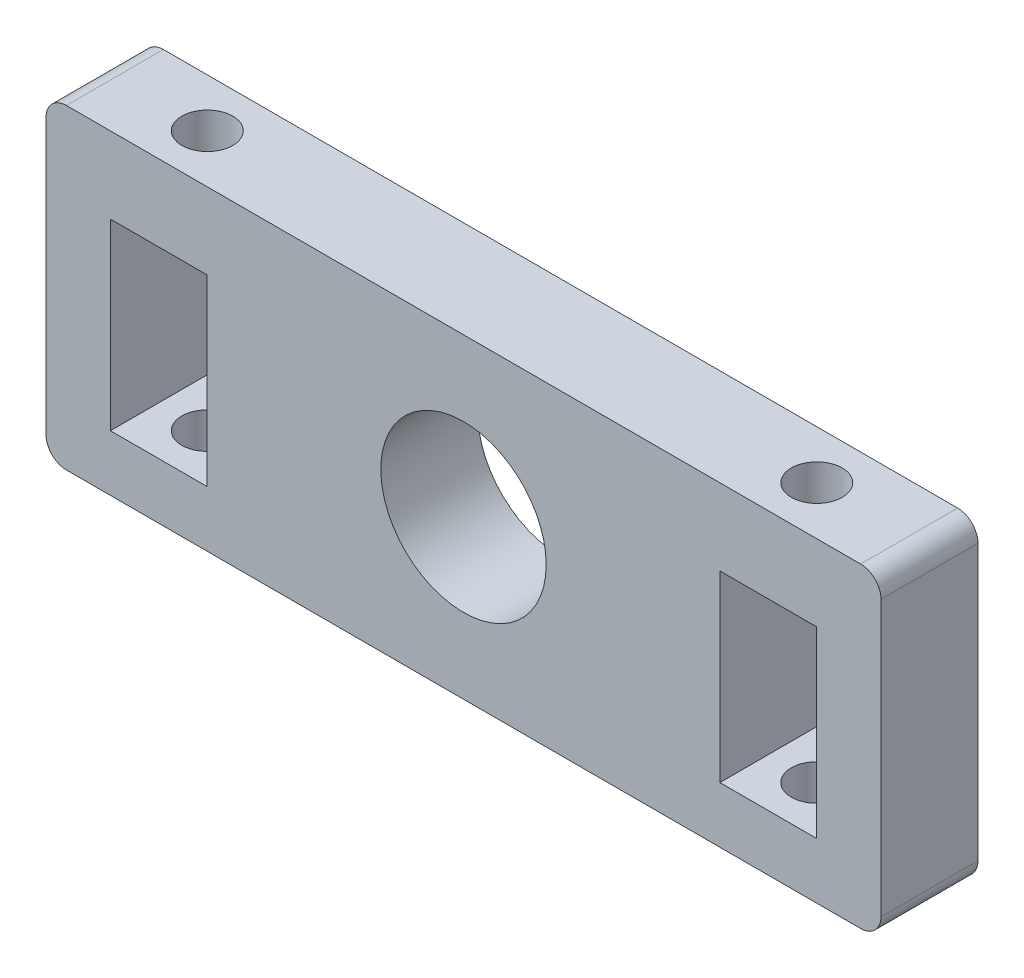
from build123d import *

# Parameters (mm, degrees)
SKETCH1_W           = 82
SKETCH1_H           = 31
BOSS_EXTRUDE2_DEPTH = 9.525
FILLET2_R           = 2
SKETCH2_R           = 8.119849814
CUT_EXTRUDE1_DEPTH  = 10.525
SKETCH3_W           = 9.5
SKETCH3_H           = 18
CUT_EXTRUDE2_DEPTH  = 10.525
SKETCH5_R           = 2.5
CUT_EXTRUDE4_DEPTH  = 30


with BuildPart() as part:
    # Sketch1 → Boss-Extrude2 (new body)
    with BuildSketch(Plane.XY):
        with Locations((0, 15.5)):
            Rectangle(SKETCH1_W, SKETCH1_H)
    extrude(amount=BOSS_EXTRUDE2_DEPTH)

    # Fillet2
    fillet2_edges = [part.edges().sort_by_distance(p)[0] for p in [
        (-41, 31, 4.7625),
        (41, 31, 4.7625),
        (41, 0, 4.7625),
        (-41, 0, 4.7625),
    ]]
    fillet(fillet2_edges, radius=FILLET2_R)

    # Sketch2 → Cut-Extrude1 (cut, through all)
    with BuildSketch(Plane.XY.offset(9.525)):
        with Locations((0, 15.5)):
            Circle(SKETCH2_R)
    extrude(amount=-CUT_EXTRUDE1_DEPTH, mode=Mode.SUBTRACT)

    # Sketch3 → Cut-Extrude2 (cut, through all)
    with BuildSketch(Plane(origin=(0, 0, 0), x_dir=(-1, 0, 0), z_dir=(0, 0, -1))):
        with Locations((-29.925, 14.5)):
            Rectangle(SKETCH3_W, SKETCH3_H)
    cut_extrude2 = extrude(amount=-CUT_EXTRUDE2_DEPTH, mode=Mode.SUBTRACT)

    # Sketch5 → Cut-Extrude4 (cut)
    with BuildSketch(Plane(origin=(0, 31, 0), x_dir=(1, 0, 0), z_dir=(0, 1, 0))):
        with Locations((-29.925, -4.76)):
            Circle(SKETCH5_R)
    cut_extrude4 = extrude(amount=-CUT_EXTRUDE4_DEPTH, mode=Mode.SUBTRACT)

    # Mirror1: Cut-Extrude2, Cut-Extrude4 across plane
    add(cut_extrude2.mirror(Plane(origin=(0, 0, 0), x_dir=(0, 0, 1), z_dir=(1, 0, 0))), mode=Mode.SUBTRACT)
    add(cut_extrude4.mirror(Plane(origin=(0, 0, 0), x_dir=(0, 0, 1), z_dir=(1, 0, 0))), mode=Mode.SUBTRACT)


solid = part.part
